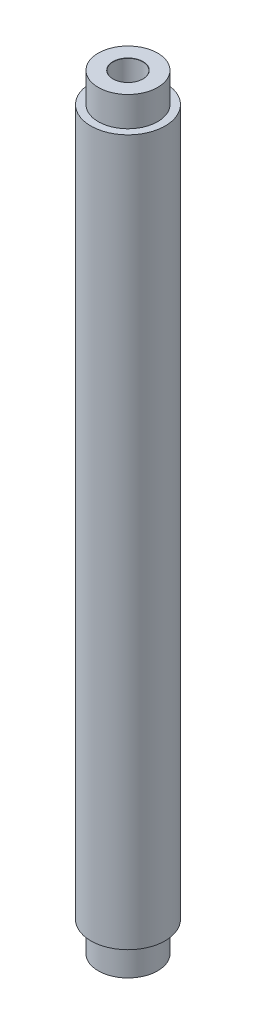
from build123d import *

# Parameters (mm, degrees)
SKETCH1_R           = 5
BOSS_EXTRUDE1_DEPTH = 103
SKETCH5_W           = 1
SKETCH5_H           = 4


with BuildPart() as part:
    # Sketch1 → Boss-Extrude1 (new body)
    with BuildSketch(Plane(origin=(0, 0, 0), x_dir=(1, 0, 0), z_dir=(0, 1, 0))):
        Circle(SKETCH1_R)
    extrude(amount=BOSS_EXTRUDE1_DEPTH)

    # Sketch4 → Ø4.0mm Dowel Hole1 (revolve, cut)
    with BuildSketch(Plane(origin=(0, 103, 0), x_dir=(0, 0, 1), z_dir=(1, 0, 0))):
        Polygon((0, 0), (0, 19.201721238), (2, 18), (2, 0.025), (2.025, 0), align=None)
    f_4_0mm_dowel_hole1 = revolve(axis=Axis((0, 109.35, 0), (0, -1, 0)), mode=Mode.SUBTRACT)

    # Mirror1: Ø4.0mm Dowel Hole1 across plane
    add(f_4_0mm_dowel_hole1.mirror(Plane.ZX.offset(51.5)), mode=Mode.SUBTRACT)

    # Sketch5 → Cut-Revolve2 (revolve, cut)
    with BuildSketch(Plane.XY):
        with Locations((-4.5, 101)):
            Rectangle(SKETCH5_W, SKETCH5_H)
        with Locations((-4.5, 2)):
            Rectangle(SKETCH5_W, SKETCH5_H)
    revolve(axis=Axis((0, 103, 0), (0, -1, 0)), mode=Mode.SUBTRACT)


solid = part.part
